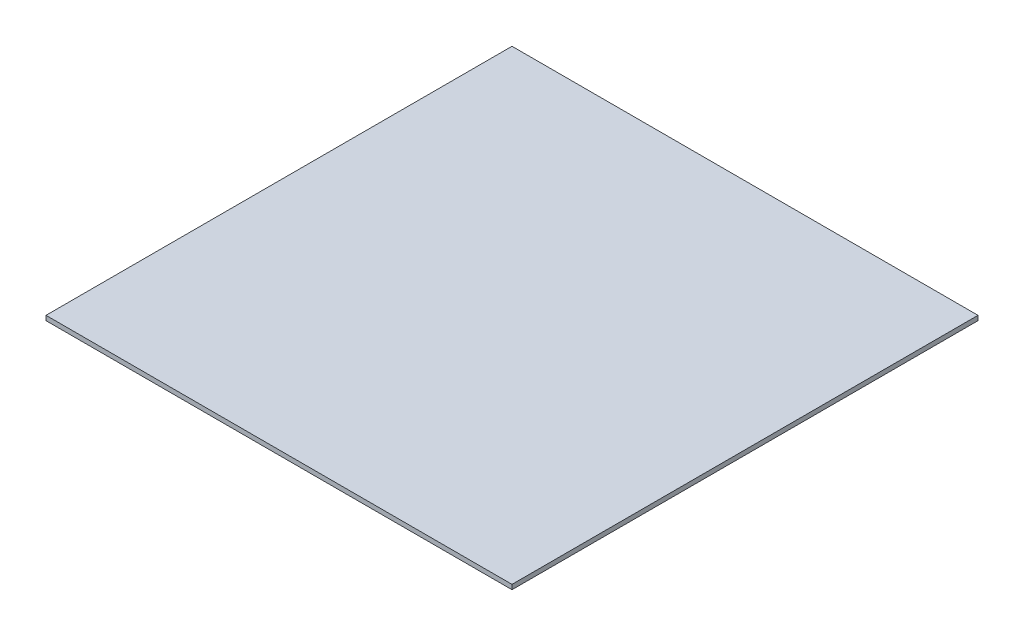
from build123d import *

# Parameters (mm, degrees)
SKETCH1_W           = 10000
SKETCH1_H           = 10000
BOSS_EXTRUDE1_DEPTH = 100


with BuildPart() as part:
    # Sketch1 → Boss-Extrude1 (new body)
    with BuildSketch(Plane(origin=(0, 0, 0), x_dir=(1, 0, 0), z_dir=(0, 1, 0))):
        Rectangle(SKETCH1_W, SKETCH1_H)
    extrude(amount=BOSS_EXTRUDE1_DEPTH)


solid = part.part
